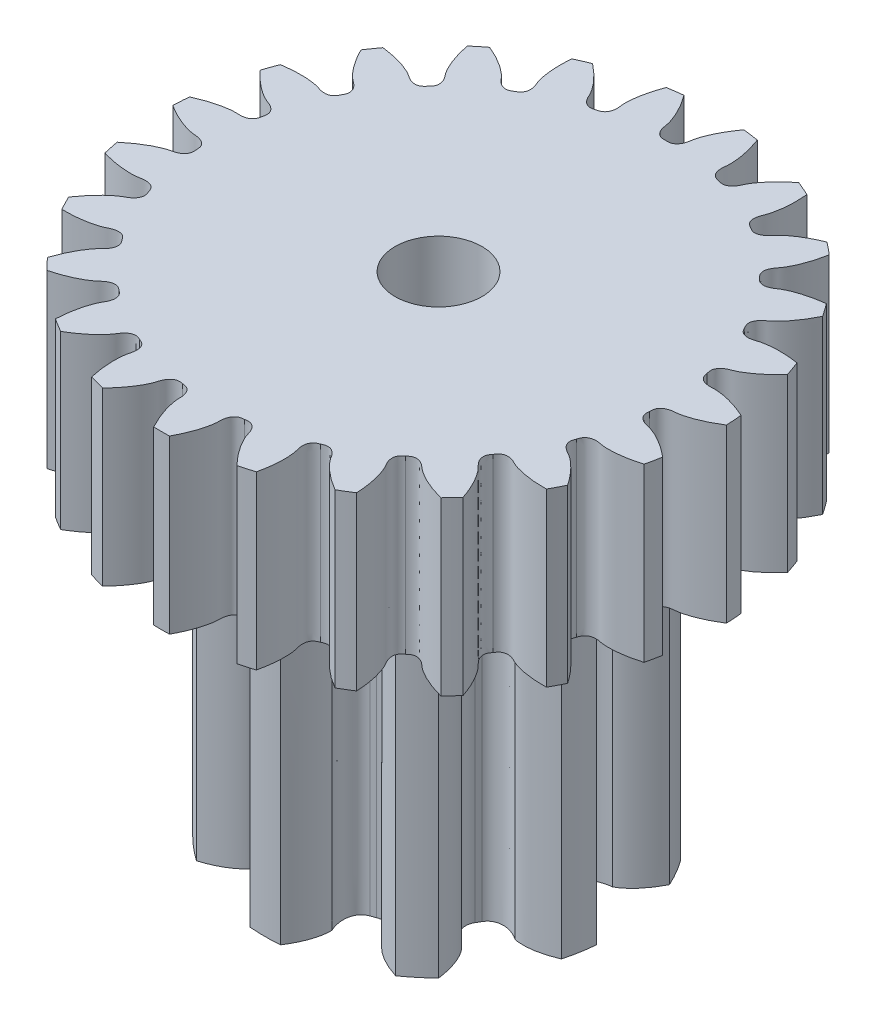
from build123d import *

# Parameters (mm, degrees)
SKETCH9_R          = 1
CUT_EXTRUDE8_DEPTH = 12.25
CUT_EXTRUDE5_DEPTH = 12.25
CIRPATTERN3_COUNT  = 23
CUT_EXTRUDE7_DEPTH = 7.3
CIRPATTERN5_COUNT  = 9


with BuildPart() as part:
    # Sketch1 → Revolve1 (revolve)
    with BuildSketch(Plane.XY):
        Polygon((-6.375, 11.25), (-6.375, 7.3), (-4, 7.3), (-4, 0), (0, 0), (0, 11.25), align=None)
    revolve(axis=Axis((0, 11.25, 0), (0, -1, 0)))

    # Sketch9 → Cut-Extrude8 (cut, through all)
    with BuildSketch(Plane(origin=(0, 11.25, 0), x_dir=(1, 0, 0), z_dir=(0, 1, 0))):
        Circle(SKETCH9_R)
    extrude(amount=-CUT_EXTRUDE8_DEPTH, mode=Mode.SUBTRACT)

    # Sketch6 → Cut-Extrude5 (cut, through all)
    with BuildSketch(Plane(origin=(0, 0, 0), x_dir=(1, 0, 0), z_dir=(0, 1, 0))):
        with BuildLine():
            ThreePointArc((-0.752729972, 6.422541773), (0, 6.466501777), (0.752729972, 6.422541773))
            add(Edge.make_bspline(
                [(0.752729972, 6.422541773), (0.699459145, 6.354890044), (0.626086373, 6.254096712), (0.540352364, 6.119053373), (0.487177939, 6.027209357), (0.442090796, 5.941439828), (0.404497927, 5.862239), (0.373780313, 5.790062373), (0.349292918, 5.725325789), (0.330374811, 5.668403086), (0.316327589, 5.619628498), (0.306486996, 5.579285648), (0.300035094, 5.547634351), (0.296507044, 5.524961298), (0.294172588, 5.507934142), (0.291854747, 5.493704547), (0.288313487, 5.474516936), (0.282184521, 5.446807654), (0.271912812, 5.411263324), (0.257007299, 5.373081074), (0.237816544, 5.336446362), (0.212441585, 5.300949008), (0.177837134, 5.267373468), (0.109819783, 5.226300491), (0.043485822, 5.224228942), (0, 5.2272159)],
                knots=[0, 0, 0, 0, 0.173174082, 0.25048394, 0.32160901, 0.386549292, 0.445304786, 0.497875492, 0.54426141, 0.584462541, 0.618478884, 0.64631044, 0.66795721, 0.683419195, 0.692448464, 0.702521063, 0.712410387, 0.731686592, 0.759573805, 0.786732767, 0.813984562, 0.842550863, 0.874111906, 0.910406194, 1, 1, 1, 1], degree=3))
            add(Edge.make_bspline(
                [(-0.752729972, 6.422541773), (-0.699459145, 6.354890044), (-0.626086373, 6.254096712), (-0.540352364, 6.119053373), (-0.487177939, 6.027209357), (-0.442090796, 5.941439828), (-0.404497927, 5.862239), (-0.373780313, 5.790062373), (-0.349292918, 5.725325789), (-0.330374811, 5.668403086), (-0.316327589, 5.619628498), (-0.306486996, 5.579285648), (-0.300035094, 5.547634351), (-0.296507044, 5.524961298), (-0.294172588, 5.507934142), (-0.291854747, 5.493704547), (-0.288313487, 5.474516936), (-0.282184521, 5.446807654), (-0.271912812, 5.411263324), (-0.257007299, 5.373081074), (-0.237816544, 5.336446362), (-0.212441585, 5.300949008), (-0.177837134, 5.267373468), (-0.109819783, 5.226300491), (-0.043485822, 5.224228942), (0, 5.2272159)],
                knots=[0, 0, 0, 0, 0.173174082, 0.25048394, 0.32160901, 0.386549292, 0.445304786, 0.497875492, 0.54426141, 0.584462541, 0.618478884, 0.64631044, 0.66795721, 0.683419195, 0.692448464, 0.702521063, 0.712410387, 0.731686592, 0.759573805, 0.786732767, 0.813984562, 0.842550863, 0.874111906, 0.910406194, 1, 1, 1, 1], degree=3))
        make_face()
    cut_extrude5 = extrude(amount=CUT_EXTRUDE5_DEPTH, mode=Mode.SUBTRACT)

    # CirPattern3: Cut-Extrude5 ×23 about axis
    cirpattern3_axis = Axis((0, 0, 0), (0, 1, 0))
    for i in range(1, CIRPATTERN3_COUNT):
        add(cut_extrude5.rotate(cirpattern3_axis, i * 360 / CIRPATTERN3_COUNT), mode=Mode.SUBTRACT)

    # Sketch8 → Cut-Extrude7 (cut)
    with BuildSketch(Plane(origin=(0, 0, 0), x_dir=(1, 0, 0), z_dir=(0, 1, 0))):
        with BuildLine():
            ThreePointArc((-1.131078751, 3.934306749), (0, 4.093666906), (1.131078751, 3.934306749))
            add(Edge.make_bspline(
                [(0.450796632, 3.137140547), (0.455529755, 3.155162412), (0.466157361, 3.18658007), (0.485696746, 3.233550019), (0.508817319, 3.281463278), (0.539206665, 3.336501478), (0.577721067, 3.397977266), (0.625147717, 3.465135457), (0.682218396, 3.53715286), (0.749598336, 3.613144103), (0.82788307, 3.692166009), (0.952284865, 3.804564297), (1.056477495, 3.88355016), (1.131078751, 3.934306749)],
                knots=[0, 0, 0, 0, 0.052407516, 0.09321295, 0.143086249, 0.202027415, 0.270036449, 0.347113351, 0.433258121, 0.528470759, 0.632751266, 0.746099642, 1, 1, 1, 1], degree=3))
            add(Edge.make_bspline(
                [(0.450796632, 3.137140547), (0.454018022, 3.084677279), (0.453600823, 3.021379384), (0.443407144, 2.928506718), (0.430898784, 2.859743031), (0.404915232, 2.77639886), (0.368534154, 2.699918209), (0.319987857, 2.630812828), (0.256565639, 2.571369181), (0.169853957, 2.523267231), (0.099718439, 2.511744849), (0.060480796, 2.511775115)],
                knots=[0, 0, 0, 0, 0.190557652, 0.22877233, 0.338905498, 0.443506794, 0.544593806, 0.644963095, 0.748129515, 0.857409087, 1, 1, 1, 1], degree=3))
            ThreePointArc((0.060480796, 2.511775115), (0, 2.512503165), (-0.060480796, 2.511775115))
            add(Edge.make_bspline(
                [(-0.450796632, 3.137140547), (-0.454018022, 3.084677279), (-0.453600823, 3.021379384), (-0.443407144, 2.928506718), (-0.430898784, 2.859743031), (-0.404915232, 2.77639886), (-0.368534154, 2.699918209), (-0.319987857, 2.630812828), (-0.256565639, 2.571369181), (-0.169853957, 2.523267231), (-0.099718439, 2.511744849), (-0.060480796, 2.511775115)],
                knots=[0, 0, 0, 0, 0.190557652, 0.22877233, 0.338905498, 0.443506794, 0.544593806, 0.644963095, 0.748129515, 0.857409087, 1, 1, 1, 1], degree=3))
            add(Edge.make_bspline(
                [(-0.450796632, 3.137140547), (-0.455529755, 3.155162412), (-0.466157361, 3.18658007), (-0.485696746, 3.233550019), (-0.508817319, 3.281463278), (-0.539206665, 3.336501478), (-0.577721067, 3.397977266), (-0.625147717, 3.465135457), (-0.682218396, 3.53715286), (-0.749598336, 3.613144103), (-0.82788307, 3.692166009), (-0.952284865, 3.804564297), (-1.056477495, 3.88355016), (-1.131078751, 3.934306749)],
                knots=[0, 0, 0, 0, 0.052407516, 0.09321295, 0.143086249, 0.202027415, 0.270036449, 0.347113351, 0.433258121, 0.528470759, 0.632751266, 0.746099642, 1, 1, 1, 1], degree=3))
        make_face()
    cut_extrude7 = extrude(amount=CUT_EXTRUDE7_DEPTH, mode=Mode.SUBTRACT)

    # CirPattern5: Cut-Extrude7 ×9 about axis
    cirpattern5_axis = Axis((0, 0, 0), (0, 1, 0))
    for i in range(1, CIRPATTERN5_COUNT):
        add(cut_extrude7.rotate(cirpattern5_axis, i * 360 / CIRPATTERN5_COUNT), mode=Mode.SUBTRACT)


solid = part.part
